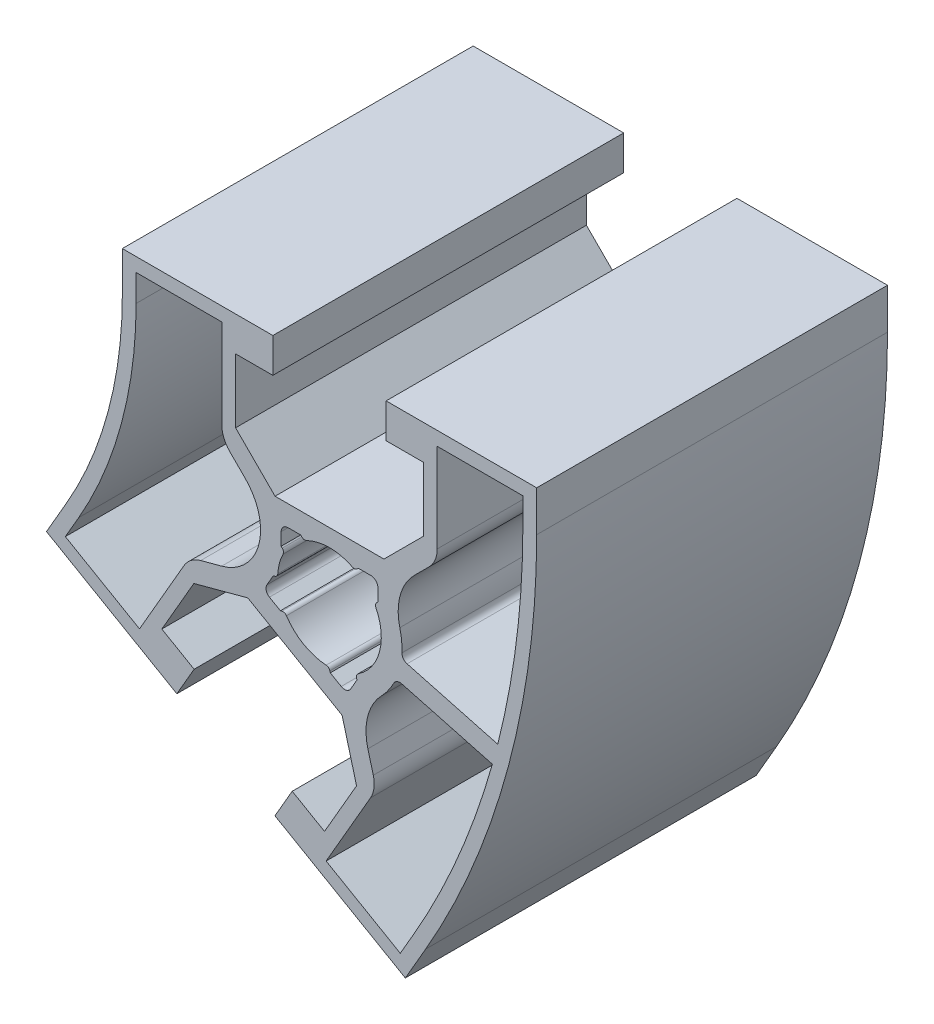
from build123d import *

# Parameters (mm, degrees)
EXTRUSION4_DEPTH = 25.4


with BuildPart() as part:
    # Sketch1 → Extrusion4 (new body)
    with BuildSketch(Plane.XY):
        with BuildLine():
            Line((-14.999999544, 15.00000004), (-4.099998054, 15.00000004))
            Line((-4.099998054, 15.00000004), (-4.099998054, 12.50000004))
            Line((-4.099998054, 12.50000004), (-6.799995004, 12.50000004))
            Line((-6.799995004, 12.50000004), (-6.799995004, 7.86065564))
            Line((-6.799995004, 7.86065564), (-3.941497574, 5.00215821))
            Line((-3.941497574, 5.00215821), (3.941498416, 5.00215821))
            Line((3.941498416, 5.00215821), (6.799995846, 7.86065564))
            Line((6.799995846, 7.86065564), (6.799995846, 12.50000004))
            Line((6.799995846, 12.50000004), (4.099998896, 12.50000004))
            Line((4.099998896, 12.50000004), (4.099998896, 15.00000004))
            Line((4.099998896, 15.00000004), (15.000000416, 15.00000004))
            Line((15.000000416, 15.00000004), (15.000000416, 12.05771371))
            ThreePointArc((15.000000416, 12.05771371), (12.955549997, -3.471428997), (6.961524646, -17.94228629))
            Line((6.961524646, -17.94228629), (5.490381513, -20.490381017))
            Line((5.490381513, -20.490381017), (-3.949296731, -15.040380238))
            Line((-3.949296731, -15.040380238), (-2.699296736, -12.875316731))
            Line((-2.699296736, -12.875316731), (-0.361030787, -14.225315201))
            Line((-0.361030787, -14.225315201), (1.958641406, -10.2075251))
            Line((1.958641406, -10.2075251), (0.912358736, -6.302745))
            Line((0.912358736, -6.302745), (-5.914516044, -2.36124701))
            Line((-5.914516044, -2.36124701), (-9.819296144, -3.40752968))
            Line((-9.819296144, -3.40752968), (-12.138968342, -7.425319789))
            Line((-12.138968342, -7.425319789), (-9.800702394, -8.775318258))
            Line((-9.800702394, -8.775318258), (-11.050702387, -10.940381761))
            Line((-11.050702387, -10.940381761), (-20.490380619, -5.490380991))
            Line((-20.490380619, -5.490380991), (-19.019237434, -2.94228629))
            ThreePointArc((-19.019237434, -2.94228629), (-16.022224761, 4.293142357), (-14.999999544, 12.05771371))
            Line((-14.999999544, 12.05771371), (-14.999999544, 15.00000004))
        make_face()
        with BuildLine():
            Line((-3.499999544, 2.08578648), (-3.499999544, 3.00000004))
            ThreePointArc((-3.499999544, 3.00000004), (-3.353552934, 3.35355343), (-2.999999544, 3.50000004))
            Line((-2.999999544, 3.50000004), (-2.085785994, 3.50000006))
            Line((-2.085785994, 3.50000006), (-2.005133554, 3.41934762))
            ThreePointArc((-2.005133554, 3.41934762), (-1.841799553, 3.33547501), (-1.660186564, 3.36248117))
            ThreePointArc((-1.660186564, 3.36248117), (4.31e-07, 3.75000007), (1.660187426, 3.36248117))
            ThreePointArc((1.660187426, 3.36248117), (1.841800416, 3.33547501), (2.005134416, 3.41934762))
            Line((2.005134416, 3.41934762), (2.085786856, 3.50000006))
            Line((2.085786856, 3.50000006), (3.000000416, 3.50000006))
            ThreePointArc((3.000000416, 3.50000006), (3.353553806, 3.35355345), (3.500000416, 3.00000006))
            Line((3.500000416, 3.00000006), (3.500000416, 2.0857865))
            Line((3.500000416, 2.0857865), (3.419347976, 2.00513406))
            ThreePointArc((3.419347976, 2.00513406), (3.335475366, 1.841800059), (3.362481526, 1.66018707))
            ThreePointArc((3.362481526, 1.66018707), (3.622222275, -0.970571346), (2.081900986, -3.11900459))
            ThreePointArc((2.081900986, -3.11900459), (1.967706477, -3.262782979), (1.958675286, -3.44617068))
            Line((1.958675286, -3.44617068), (1.988196126, -3.55634396))
            Line((1.988196126, -3.55634396), (1.531089346, -4.34807613))
            ThreePointArc((1.531089346, -4.34807613), (1.227486167, -4.58103904), (0.848076646, -4.53108883))
            Line((0.848076646, -4.53108883), (0.056344476, -4.07398205))
            Line((0.056344476, -4.07398205), (0.026823636, -3.96380877))
            ThreePointArc((0.026823636, -3.96380877), (-0.072691445, -3.809505949), (-0.243475994, -3.74208748))
            ThreePointArc((-0.243475994, -3.74208748), (-1.874999553, -3.247595194), (-3.119004214, -2.08190049))
            ThreePointArc((-3.119004214, -2.08190049), (-3.262782603, -1.967705981), (-3.446170304, -1.95867479))
            Line((-3.446170304, -1.95867479), (-3.556343584, -1.98819563))
            Line((-3.556343584, -1.98819563), (-4.348075754, -1.53108885))
            ThreePointArc((-4.348075754, -1.53108885), (-4.581038663, -1.227485671), (-4.531088454, -0.84807615))
            Line((-4.531088454, -0.84807615), (-4.073981674, -0.05634398))
            Line((-4.073981674, -0.05634398), (-3.963808394, -0.02682314))
            ThreePointArc((-3.963808394, -0.02682314), (-3.809505572, 0.072691941), (-3.742087104, 0.24347649))
            ThreePointArc((-3.742087104, 0.24347649), (-3.622221403, 0.970571473), (-3.362480654, 1.66018705))
            ThreePointArc((-3.362480654, 1.66018705), (-3.335474493, 1.841800039), (-3.419347104, 2.00513404))
            Line((-3.419347104, 2.00513404), (-3.499999544, 2.08578648))
        make_face(mode=Mode.SUBTRACT)
        with BuildLine():
            Line((7.799995876, 7.56776241), (7.799995866, 14.00000004))
            Line((7.799995866, 14.00000004), (14.000000436, 14.00000004))
            Line((14.000000436, 14.00000004), (14.000000436, 12.05771371))
            ThreePointArc((14.000000436, 12.05771371), (13.543013967, 4.72862326), (12.179133767, -2.486931761))
            Line((12.179133767, -2.486931761), (5.615359986, -0.72817388))
            ThreePointArc((5.615359986, -0.72817388), (5.341691374, -0.541062306), (5.245224376, -0.22388827))
            ThreePointArc((5.245224376, -0.22388827), (5.222856323, 0.533175972), (5.091787186, 1.27914345))
            ThreePointArc((5.091787186, 1.27914345), (5.115773337, 3.319255981), (6.142816616, 5.08215603))
            Line((6.142816616, 5.08215603), (7.214209436, 6.15354885))
            ThreePointArc((7.214209436, 6.15354885), (7.647754936, 6.802395548), (7.799995876, 7.56776241))
        make_face(mode=Mode.SUBTRACT)
        with BuildLine():
            Line((5.227131414, -2.177062614), (11.790905183, -3.935820492))
            ThreePointArc((11.790905183, -3.935820492), (9.364282579, -10.866614542), (6.095499246, -17.44228629))
            Line((6.095499246, -17.44228629), (5.124356099, -19.124355612))
            Line((5.124356099, -19.124355612), (-0.245005373, -16.024353311))
            Line((-0.245005373, -16.024353311), (2.971113436, -10.45387213))
            ThreePointArc((2.971113436, -10.45387213), (3.221952356, -9.714924516), (3.170914286, -8.93623404))
            Line((3.170914286, -8.93623404), (2.778757296, -7.47268423))
            ThreePointArc((2.778757296, -7.47268423), (2.770761748, -5.432446365), (3.770045396, -3.65366401))
            ThreePointArc((3.770045396, -3.65366401), (4.256538339, -3.07317179), (4.654441766, -2.42871895))
            ThreePointArc((4.654441766, -2.42871895), (4.896571658, -2.202271683), (5.227131414, -2.177062614))
        make_face(mode=Mode.SUBTRACT)
        with BuildLine():
            Line((-13.999999544, 14.00000005), (-7.799994974, 14.00000005))
            Line((-7.799994974, 14.00000005), (-7.799994974, 7.56776243))
            ThreePointArc((-7.799994974, 7.56776243), (-7.647754043, 6.802395559), (-7.214208534, 6.15354886))
            Line((-7.214208534, 6.15354886), (-6.102918804, 5.04225913))
            ThreePointArc((-6.102918804, 5.04225913), (-5.119406434, 1.371740988), (-7.806412204, -1.31526478))
            Line((-7.806412204, -1.31526478), (-9.324462204, -1.72202505))
            ThreePointArc((-9.324462204, -1.72202505), (-10.024346973, -2.06717002), (-10.538874924, -2.6538767))
            Line((-10.538874924, -2.6538767), (-13.754993733, -8.224357881))
            Line((-13.754993733, -8.224357881), (-19.124355202, -5.12435558))
            Line((-19.124355202, -5.12435558), (-18.153212024, -3.44228628))
            ThreePointArc((-18.153212024, -3.44228628), (-15.056298932, 4.034323322), (-13.999999544, 12.05771372))
            Line((-13.999999544, 12.05771372), (-13.999999544, 14.00000005))
        make_face(mode=Mode.SUBTRACT)
    extrude(amount=EXTRUSION4_DEPTH)


solid = part.part
